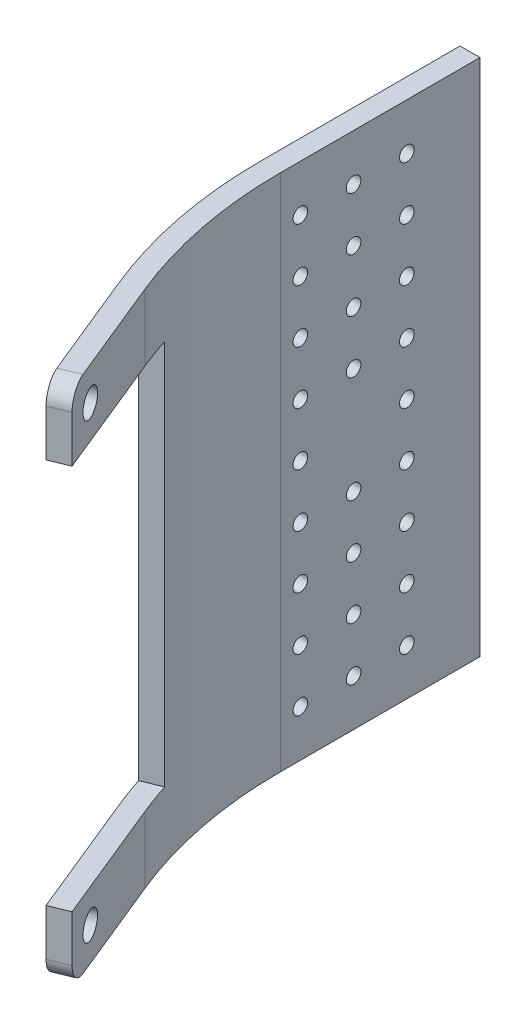
from build123d import *

# Parameters (mm, degrees)
EXTRUSION1_DEPTH = 78
EXTRUSION3_REACH = 32.949
ESQUISSE2_R      = 2
ESQUISSE2_W      = 25
ESQUISSE2_H      = 58
CONG_1_R         = 3
ESQUISSE3_R      = 1.1
EXTRUSION4_DEPTH = 3


with BuildPart() as part:
    # Esquisse1 → Extrusion1 (new body)
    with BuildSketch(Plane(origin=(0, 0, 0), x_dir=(1, 0, 0), z_dir=(0, 1, 0))):
        with BuildLine():
            Line((0, 0), (0, 30))
            Line((0, 30), (3, 30))
            Line((3, 30), (3, 0))
            ThreePointArc((3, 0), (4.257195182, -12.918344113), (7.981600437, -25.351885839))
            Line((7.981600437, -25.351885839), (15.549327553, -43.864840933))
            Line((15.549327553, -43.864840933), (12.772384289, -45))
            Line((12.772384289, -45), (5.204657173, -26.487044906))
            ThreePointArc((5.204657173, -26.487044906), (1.313487503, -13.496777432), (0, 0))
        make_face()
    extrude(amount=EXTRUSION1_DEPTH)

    # Esquisse2 → Extrusion3 (cut, up to next)
    with BuildSketch(Plane(origin=(-4.817679226, 0, 1.969371261), x_dir=(0.378386356, 0, 0.925647755), z_dir=(-0.925647755, 0, 0.378386356)), mode=Mode.PRIVATE) as extrusion3_sk1:
        with Locations((41.487044906, 5)):
            Circle(ESQUISSE2_R)
    extrusion3_tool1 = extrude(extrusion3_sk1.sketch, amount=-EXTRUSION3_REACH, mode=Mode.PRIVATE) & part.part
    add(extrusion3_tool1.solids().sort_by_distance((10.880453, 5, 40.371761))[0], mode=Mode.SUBTRACT)
    # Esquisse2 → Extrusion3 (cut, up to next)
    with BuildSketch(Plane(origin=(-4.817679226, 0, 1.969371261), x_dir=(0.378386356, 0, 0.925647755), z_dir=(-0.925647755, 0, 0.378386356)), mode=Mode.PRIVATE) as extrusion3_sk2:
        with Locations((41.487044906, 73)):
            Circle(ESQUISSE2_R)
    extrusion3_tool2 = extrude(extrusion3_sk2.sketch, amount=-EXTRUSION3_REACH, mode=Mode.PRIVATE) & part.part
    add(extrusion3_tool2.solids().sort_by_distance((10.880453, 73, 40.371761))[0], mode=Mode.SUBTRACT)
    # Esquisse2 → Extrusion3 (cut, up to next)
    with BuildSketch(Plane(origin=(-4.817679226, 0, 1.969371261), x_dir=(0.378386356, 0, 0.925647755), z_dir=(-0.925647755, 0, 0.378386356)), mode=Mode.PRIVATE) as extrusion3_sk3:
        with Locations((33.987044906, 39)):
            Rectangle(ESQUISSE2_W, ESQUISSE2_H)
    extrusion3_tool3 = extrude(extrusion3_sk3.sketch, amount=-EXTRUSION3_REACH, mode=Mode.PRIVATE) & part.part
    add(extrusion3_tool3.solids().sort_by_distance((8.042555, 39, 33.429403))[0], mode=Mode.SUBTRACT)

    # Congé1
    cong_1_edges = [part.edges().sort_by_distance(p)[0] for p in [
        (14.160855921, 78, 44.432420466),
        (14.160855921, 0, 44.432420466),
    ]]
    fillet(cong_1_edges, radius=CONG_1_R)

    # Esquisse3 → Extrusion4 (cut)
    with BuildSketch(Plane(origin=(3, 0, 0), x_dir=(0, 0, -1), z_dir=(1, 0, 0))):
        with Locations((3, 31)):
            Circle(ESQUISSE3_R)
        with Locations((11, 31)):
            Circle(ESQUISSE3_R)
        with Locations((19, 31)):
            Circle(ESQUISSE3_R)
        with Locations((3, 39)):
            Circle(ESQUISSE3_R)
        with Locations((19, 39)):
            Circle(ESQUISSE3_R)
        with Locations((19, 47)):
            Circle(ESQUISSE3_R)
        with Locations((11, 47)):
            Circle(ESQUISSE3_R)
        with Locations((3, 47)):
            Circle(ESQUISSE3_R)
        with Locations((3, 23)):
            Circle(ESQUISSE3_R)
        with Locations((11, 23)):
            Circle(ESQUISSE3_R)
        with Locations((19, 23)):
            Circle(ESQUISSE3_R)
        with Locations((3, 15)):
            Circle(ESQUISSE3_R)
        with Locations((11, 15)):
            Circle(ESQUISSE3_R)
        with Locations((19, 15)):
            Circle(ESQUISSE3_R)
        with Locations((3, 7)):
            Circle(ESQUISSE3_R)
        with Locations((11, 7)):
            Circle(ESQUISSE3_R)
        with Locations((19, 7)):
            Circle(ESQUISSE3_R)
        with Locations((3, 71)):
            Circle(ESQUISSE3_R)
        with Locations((3, 55)):
            Circle(ESQUISSE3_R)
        with Locations((3, 63)):
            Circle(ESQUISSE3_R)
        with Locations((11, 71)):
            Circle(ESQUISSE3_R)
        with Locations((11, 63)):
            Circle(ESQUISSE3_R)
        with Locations((11, 55)):
            Circle(ESQUISSE3_R)
        with Locations((19, 55)):
            Circle(ESQUISSE3_R)
        with Locations((19, 63)):
            Circle(ESQUISSE3_R)
        with Locations((19, 71)):
            Circle(ESQUISSE3_R)
    extrude(amount=-EXTRUSION4_DEPTH, mode=Mode.SUBTRACT)


solid = part.part
